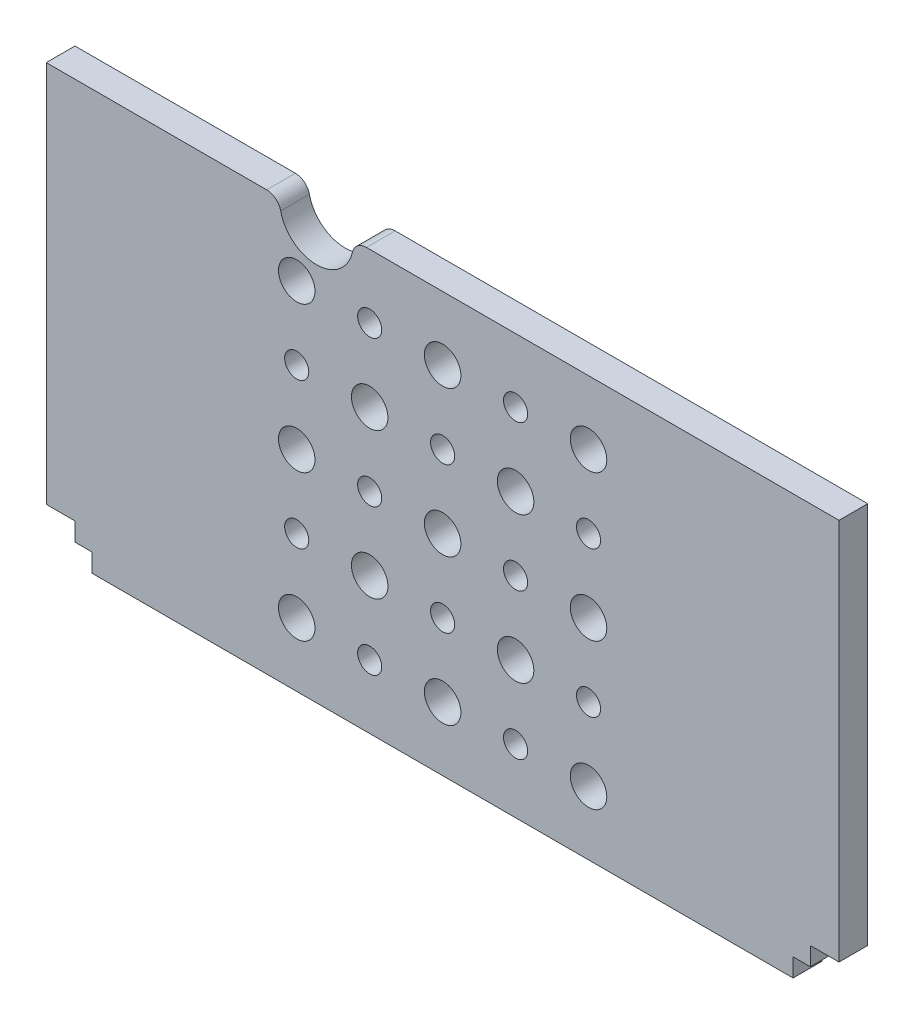
from build123d import *

# Parameters (mm, degrees)
BOSS_EXTRUDE1_DEPTH = 5


with BuildPart() as part:
    # Sketch1 → Boss-Extrude1 (new body)
    with BuildSketch(Plane.XY):
        with BuildLine():
            Line((-30.63374919, 36.5), (-69, 36.5))
            Line((-69, 36.5), (-69, -30.1))
            Line((-69, -30.1), (-64, -30.1))
            Line((-64, -30.1), (-64, -33.3))
            Line((-64, -33.3), (-61, -33.3))
            Line((-61, -33.3), (-61, -36.5))
            Line((-61, -36.5), (61, -36.5))
            Line((61, -36.5), (61, -33.3))
            Line((61, -33.3), (64, -33.3))
            Line((64, -33.3), (64, -30.1))
            Line((64, -30.1), (69, -30.1))
            Line((69, -30.1), (69, 36.5))
            Line((69, 36.5), (-13.26625081, 36.5))
            ThreePointArc((-13.26625081, 36.5), (-14.828399647, 35.951842978), (-15.7055062, 34.547752809))
            ThreePointArc((-15.7055062, 34.547752809), (-21.95, 29.55), (-28.1944938, 34.547752809))
            ThreePointArc((-28.1944938, 34.547752809), (-29.071600353, 35.951842978), (-30.63374919, 36.5))
        make_face()
        with BuildLine():
            ThreePointArc((3.175, -25.4), (0, -22.225), (-3.175, -25.4))
            ThreePointArc((-3.175, -25.4), (0, -28.575), (3.175, -25.4))
        make_face(mode=Mode.SUBTRACT)
        with BuildLine():
            ThreePointArc((-3.175, 0), (0, -3.175), (3.175, 0))
            ThreePointArc((3.175, 0), (0, 3.175), (-3.175, 0))
        make_face(mode=Mode.SUBTRACT)
        with BuildLine():
            ThreePointArc((-22.225, -25.4), (-25.4, -22.225), (-28.575, -25.4))
            ThreePointArc((-28.575, -25.4), (-25.4, -28.575), (-22.225, -25.4))
        make_face(mode=Mode.SUBTRACT)
        with BuildLine():
            ThreePointArc((28.575, -25.4), (25.4, -22.225), (22.225, -25.4))
            ThreePointArc((22.225, -25.4), (25.4, -28.575), (28.575, -25.4))
        make_face(mode=Mode.SUBTRACT)
        with BuildLine():
            ThreePointArc((-9.525, -12.7), (-12.7, -9.525), (-15.875, -12.7))
            ThreePointArc((-15.875, -12.7), (-12.7, -15.875), (-9.525, -12.7))
        make_face(mode=Mode.SUBTRACT)
        with BuildLine():
            ThreePointArc((-23.3, -12.7), (-25.4, -10.6), (-27.5, -12.7))
            ThreePointArc((-27.5, -12.7), (-25.4, -14.8), (-23.3, -12.7))
        make_face(mode=Mode.SUBTRACT)
        with BuildLine():
            ThreePointArc((14.8, -25.4), (12.7, -23.3), (10.6, -25.4))
            ThreePointArc((10.6, -25.4), (12.7, -27.5), (14.8, -25.4))
        make_face(mode=Mode.SUBTRACT)
        with BuildLine():
            ThreePointArc((-10.6, -25.4), (-12.7, -23.3), (-14.8, -25.4))
            ThreePointArc((-14.8, -25.4), (-12.7, -27.5), (-10.6, -25.4))
        make_face(mode=Mode.SUBTRACT)
        with BuildLine():
            ThreePointArc((2.1, -12.7), (0, -10.6), (-2.1, -12.7))
            ThreePointArc((-2.1, -12.7), (0, -14.8), (2.1, -12.7))
        make_face(mode=Mode.SUBTRACT)
        with BuildLine():
            ThreePointArc((-10.6, 25.4), (-12.7, 27.5), (-14.8, 25.4))
            ThreePointArc((-14.8, 25.4), (-12.7, 23.3), (-10.6, 25.4))
        make_face(mode=Mode.SUBTRACT)
        with BuildLine():
            ThreePointArc((-22.225, 25.4), (-25.4, 28.575), (-28.575, 25.4))
            ThreePointArc((-28.575, 25.4), (-25.4, 22.225), (-22.225, 25.4))
        make_face(mode=Mode.SUBTRACT)
        with BuildLine():
            ThreePointArc((28.575, 25.4), (25.4, 28.575), (22.225, 25.4))
            ThreePointArc((22.225, 25.4), (25.4, 22.225), (28.575, 25.4))
        make_face(mode=Mode.SUBTRACT)
        with BuildLine():
            ThreePointArc((27.5, 12.7), (25.4, 14.8), (23.3, 12.7))
            ThreePointArc((23.3, 12.7), (25.4, 10.6), (27.5, 12.7))
        make_face(mode=Mode.SUBTRACT)
        with BuildLine():
            ThreePointArc((28.575, 0), (25.4, 3.175), (22.225, 0))
            ThreePointArc((22.225, 0), (25.4, -3.175), (28.575, 0))
        make_face(mode=Mode.SUBTRACT)
        with BuildLine():
            ThreePointArc((23.3, -12.7), (25.4, -14.8), (27.5, -12.7))
            ThreePointArc((27.5, -12.7), (25.4, -10.6), (23.3, -12.7))
        make_face(mode=Mode.SUBTRACT)
        with BuildLine():
            ThreePointArc((10.6, 0), (12.7, -2.1), (14.8, 0))
            ThreePointArc((14.8, 0), (12.7, 2.1), (10.6, 0))
        make_face(mode=Mode.SUBTRACT)
        with BuildLine():
            ThreePointArc((9.525, 12.7), (12.7, 9.525), (15.875, 12.7))
            ThreePointArc((15.875, 12.7), (12.7, 15.875), (9.525, 12.7))
        make_face(mode=Mode.SUBTRACT)
        with BuildLine():
            ThreePointArc((10.6, 25.4), (12.7, 23.3), (14.8, 25.4))
            ThreePointArc((14.8, 25.4), (12.7, 27.5), (10.6, 25.4))
        make_face(mode=Mode.SUBTRACT)
        with BuildLine():
            ThreePointArc((3.175, 25.4), (0, 28.575), (-3.175, 25.4))
            ThreePointArc((-3.175, 25.4), (0, 22.225), (3.175, 25.4))
        make_face(mode=Mode.SUBTRACT)
        with BuildLine():
            ThreePointArc((2.1, 12.7), (0, 14.8), (-2.1, 12.7))
            ThreePointArc((-2.1, 12.7), (0, 10.6), (2.1, 12.7))
        make_face(mode=Mode.SUBTRACT)
        with BuildLine():
            ThreePointArc((-27.5, 12.7), (-25.4, 10.6), (-23.3, 12.7))
            ThreePointArc((-23.3, 12.7), (-25.4, 14.8), (-27.5, 12.7))
        make_face(mode=Mode.SUBTRACT)
        with BuildLine():
            ThreePointArc((-9.525, 12.7), (-12.7, 15.875), (-15.875, 12.7))
            ThreePointArc((-15.875, 12.7), (-12.7, 9.525), (-9.525, 12.7))
        make_face(mode=Mode.SUBTRACT)
        with BuildLine():
            ThreePointArc((-10.6, 0), (-12.7, 2.1), (-14.8, 0))
            ThreePointArc((-14.8, 0), (-12.7, -2.1), (-10.6, 0))
        make_face(mode=Mode.SUBTRACT)
        with BuildLine():
            ThreePointArc((9.525, -12.7), (12.7, -15.875), (15.875, -12.7))
            ThreePointArc((15.875, -12.7), (12.7, -9.525), (9.525, -12.7))
        make_face(mode=Mode.SUBTRACT)
        with BuildLine():
            ThreePointArc((-28.575, 0), (-25.4, -3.175), (-22.225, 0))
            ThreePointArc((-22.225, 0), (-25.4, 3.175), (-28.575, 0))
        make_face(mode=Mode.SUBTRACT)
    extrude(amount=-BOSS_EXTRUDE1_DEPTH)


solid = part.part
